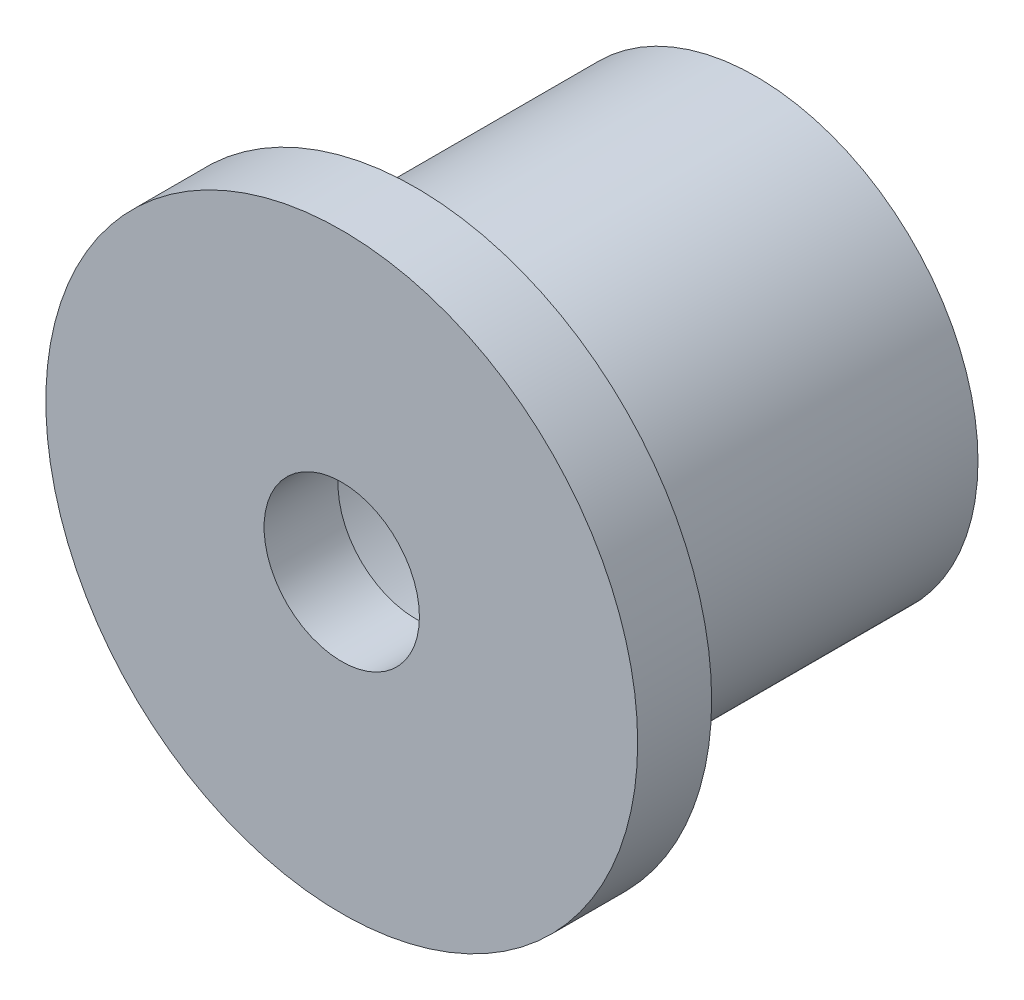
from build123d import *


with BuildPart() as part:
    # Эскиз1 → Повернуть1 (revolve)
    with BuildSketch(Plane(origin=(0, 0, 0), x_dir=(0, 0, -1), z_dir=(1, 0, 0))):
        Polygon((0, 12.5), (-23, 12.5), (-23, 5.25), (-28, 5.25), (-28, 20), (-23, 20), (-23, 15), (0, 15), align=None)
    revolve(axis=Axis((0, 0, 1000), (0, 0, -1)))


solid = part.part
